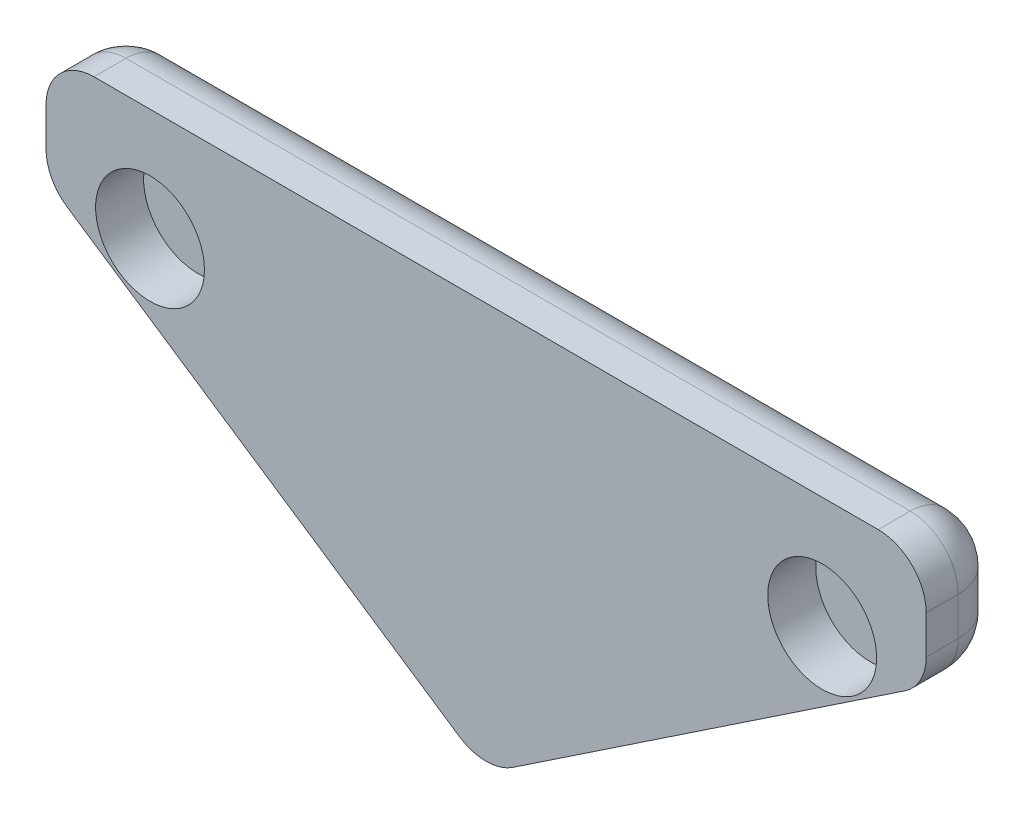
from build123d import *

# Parameters (mm, degrees)
BOSS_EXTRUDE1_DEPTH = 2.5
SKETCH2_R           = 1.7
CUT_EXTRUDE1_DEPTH  = 1.5
FILLET1_R           = 1.5


with BuildPart() as part:
    # Sketch1 → Boss-Extrude1 (new body)
    with BuildSketch(Plane.XY):
        Polygon((-7.56419618, 12.7), (-7.56419618, 9.2), (6.18580382, 0), (6.18580382, 12.7), align=None)
    extrude(amount=BOSS_EXTRUDE1_DEPTH)

    # Sketch2 → Cut-Extrude1 (cut)
    with BuildSketch(Plane.XY.offset(2.5)):
        with Locations((-4.31419618, 9.2)):
            Circle(SKETCH2_R)
    extrude(amount=-CUT_EXTRUDE1_DEPTH, mode=Mode.SUBTRACT)

    # Mirror2: part across plane


with BuildPart() as part_1:
    add(part.part)
    add(part.part.mirror(Plane(origin=(6.18580382, 0, 2.5), x_dir=(0, 0, 1), z_dir=(-1, 0, 0))))

    # Fillet1
    fillet1_edges = [part_1.edges().sort_by_distance(p)[0] for p in [
        (19.93580382, 12.7, 1.25),
        (19.93580382, 9.2, 1.25),
        (6.18580382, 0, 1.25),
        (19.93580382, 10.95, 0),
        (13.06080382, 4.6, 0),
        (-0.68919618, 4.6, 0),
        (-7.56419618, 10.95, 0),
        (6.18580382, 12.7, 0),
        (-7.56419618, 9.2, 1.25),
        (-7.56419618, 12.7, 1.25),
    ]]
    fillet(fillet1_edges, radius=FILLET1_R)


solid = part_1.part
